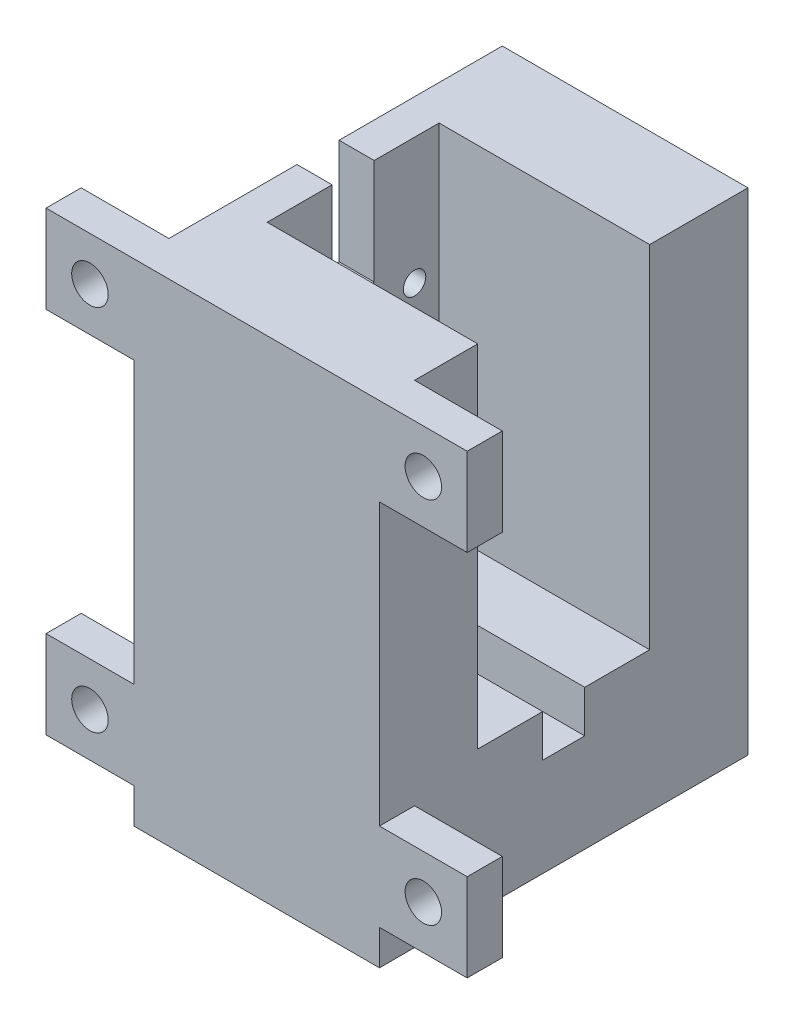
from build123d import *

# Parameters (mm, degrees)
SKETCH1_W                = 40
SKETCH1_H                = 65
BOSS_EXTRUDE1_DEPTH      = 42.5
BOSS_EXTRUDE1_DEPTH_BACK = 15
SKETCH3_W                = 22.5
SKETCH3_H                = 50
CUT_EXTRUDE2_DEPTH       = 30
SKETCH4_R                = 4.5
CUT_EXTRUDE3_DEPTH       = 10
SKETCH6_W                = 40
SKETCH6_H                = 65
CUT_EXTRUDE4_DEPTH       = 5
SKETCH7_R                = 3
CUT_EXTRUDE5_DEPTH       = 10
SKETCH8_W                = 52.5
SKETCH8_H                = 65
CUT_EXTRUDE6_DEPTH       = 5
SKETCH9_W                = 12.5
SKETCH9_H                = 12.5
SKETCH9_R                = 2.6
BOSS_EXTRUDE2_DEPTH      = 5
SKETCH10_R               = 3
BOSS_EXTRUDE3_DEPTH      = 5
SKETCH11_R               = 1.6
CUT_EXTRUDE7_DEPTH       = 18.5
SKETCH12_W               = 30
SKETCH12_H               = 50
CUT_EXTRUDE8_DEPTH       = 12.25
CUT_EXTRUDE8_DEPTH_BACK  = 12.25
CUT_EXTRUDE9_DEPTH       = 30
CUT_EXTRUDE10_DEPTH      = 15


with BuildPart() as part:
    # Sketch1 → Boss-Extrude1 (new body, two sides)
    with BuildSketch(Plane.XY) as boss_extrude1_sk:
        with Locations((20, 32.5)):
            Rectangle(SKETCH1_W, SKETCH1_H)
    extrude(amount=BOSS_EXTRUDE1_DEPTH)
    extrude(boss_extrude1_sk.sketch, amount=-BOSS_EXTRUDE1_DEPTH_BACK)

    # Sketch3 → Cut-Extrude2 (cut)
    with BuildSketch(Plane(origin=(40, 0, 0), x_dir=(0, 0, -1), z_dir=(1, 0, 0))):
        with Locations((-11.25, 40)):
            Rectangle(SKETCH3_W, SKETCH3_H)
    extrude(amount=-CUT_EXTRUDE2_DEPTH, mode=Mode.SUBTRACT)

    # Sketch4 → Cut-Extrude3 (cut)
    with BuildSketch(Plane(origin=(10, 0, 0), x_dir=(0, 0, -1), z_dir=(1, 0, 0))):
        with Locations((-11.25, 26.5)):
            Circle(SKETCH4_R)
    extrude(amount=-CUT_EXTRUDE3_DEPTH, mode=Mode.SUBTRACT)

    # Sketch6 → Cut-Extrude4 (cut)
    with BuildSketch(Plane.XY.offset(42.5)):
        with Locations((20, 32.5)):
            Rectangle(SKETCH6_W, SKETCH6_H)
    extrude(amount=-CUT_EXTRUDE4_DEPTH, mode=Mode.SUBTRACT)

    # Sketch7 → Cut-Extrude5 (cut)
    with BuildSketch(Plane.XZ):
        with Locations((28, 25.5)):
            Circle(SKETCH7_R)
        with Locations((28, -3)):
            Circle(SKETCH7_R)
    extrude(amount=-CUT_EXTRUDE5_DEPTH, mode=Mode.SUBTRACT)

    # Sketch8 → Cut-Extrude6 (cut)
    with BuildSketch(Plane.ZY):
        with Locations((11.25, 32.5)):
            Rectangle(SKETCH8_W, SKETCH8_H)
    extrude(amount=-CUT_EXTRUDE6_DEPTH, mode=Mode.SUBTRACT)

    # Sketch9 → Boss-Extrude2 (add)
    with BuildSketch(Plane.XY.offset(37.5)):
        with Locations((-1.25, 58.75)):
            Rectangle(SKETCH9_W, SKETCH9_H)
        with Locations((-1.25, 58.75)):
            Circle(SKETCH9_R, mode=Mode.SUBTRACT)
        with Locations((46.25, 58.75)):
            Rectangle(SKETCH9_W, SKETCH9_H)
        with Locations((46.25, 58.75)):
            Circle(SKETCH9_R, mode=Mode.SUBTRACT)
        with Locations((46.25, 6.25)):
            Rectangle(SKETCH9_W, SKETCH9_H)
        with Locations((46.25, 6.25)):
            Circle(SKETCH9_R, mode=Mode.SUBTRACT)
        with Locations((-1.25, 6.25)):
            Rectangle(SKETCH9_W, SKETCH9_H)
        with Locations((-1.25, 6.25)):
            Circle(SKETCH9_R, mode=Mode.SUBTRACT)
    extrude(amount=-BOSS_EXTRUDE2_DEPTH)

    # Sketch10 → Boss-Extrude3 (add)
    with BuildSketch(Plane.XZ):
        Polygon((40, 32.5), (40, 37.5), (5, 37.5), (5, -15), (40, -15), align=None)
        with Locations((28, 25.5)):
            Circle(SKETCH10_R, mode=Mode.SUBTRACT)
        with Locations((28, -3)):
            Circle(SKETCH10_R, mode=Mode.SUBTRACT)
    extrude(amount=BOSS_EXTRUDE3_DEPTH)

    # Sketch11 → Cut-Extrude7 (cut, through all)
    with BuildSketch(Plane(origin=(10, 0, 0), x_dir=(0, 0, -1), z_dir=(1, 0, 0))):
        with Locations((-2.5, 47)):
            Circle(SKETCH11_R)
        with Locations((-20, 47)):
            Circle(SKETCH11_R)
    extrude(amount=-CUT_EXTRUDE7_DEPTH, mode=Mode.SUBTRACT)

    # Sketch12 → Cut-Extrude8 (cut, two sides)
    with BuildSketch(Plane(origin=(0, 0, 11.25), x_dir=(-1, 0, 0), z_dir=(0, 0, -1))) as cut_extrude8_sk:
        with Locations((-25, 40)):
            Rectangle(SKETCH12_W, SKETCH12_H)
    extrude(amount=CUT_EXTRUDE8_DEPTH, mode=Mode.SUBTRACT)
    extrude(cut_extrude8_sk.sketch, amount=-CUT_EXTRUDE8_DEPTH_BACK, mode=Mode.SUBTRACT)

    # Sketch13 → Cut-Extrude9 (cut)
    with BuildSketch(Plane(origin=(40, 0, 0), x_dir=(0, 0, -1), z_dir=(1, 0, 0))):
        Polygon((-11.25, 15), (-8.25, 15), (-8.25, 9), (-14.25, 9), (-14.25, 15), align=None)
    extrude(amount=-CUT_EXTRUDE9_DEPTH, mode=Mode.SUBTRACT)

    # Sketch14 → Cut-Extrude10 (cut)
    with BuildSketch(Plane(origin=(0, 65, 0), x_dir=(1, 0, 0), z_dir=(0, 1, 0))):
        Polygon((5, -11.25), (5, -8.25), (10, -8.25), (10, -14.25), (5, -14.25), align=None)
    extrude(amount=-CUT_EXTRUDE10_DEPTH, mode=Mode.SUBTRACT)


solid = part.part
